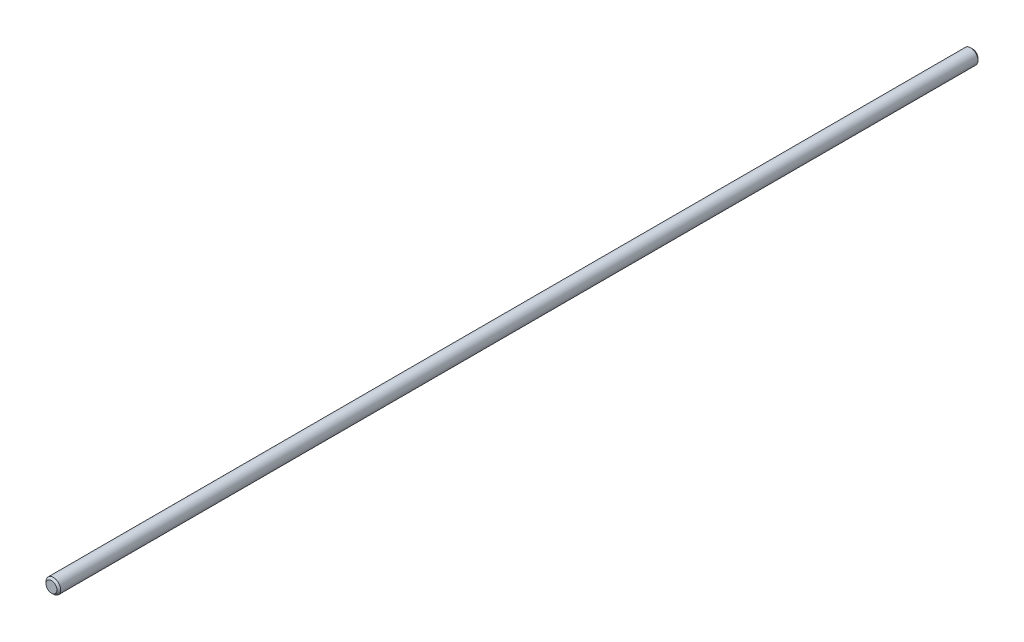
from build123d import *

# Parameters (mm, degrees)
SKETCH1_R           = 3.975
BOSS_EXTRUDE1_DEPTH = 500
CHAMFER1_SIZE       = 1


with BuildPart() as part:
    # Sketch1 → Boss-Extrude1 (new body)
    with BuildSketch(Plane.XY):
        Circle(SKETCH1_R)
    extrude(amount=BOSS_EXTRUDE1_DEPTH)

    # Chamfer1
    chamfer1_edges = [part.edges().sort_by_distance(p)[0] for p in [
        (-3.975, 0, 0),
        (-3.975, 0, 500),
    ]]
    chamfer(chamfer1_edges, length=CHAMFER1_SIZE)


solid = part.part
